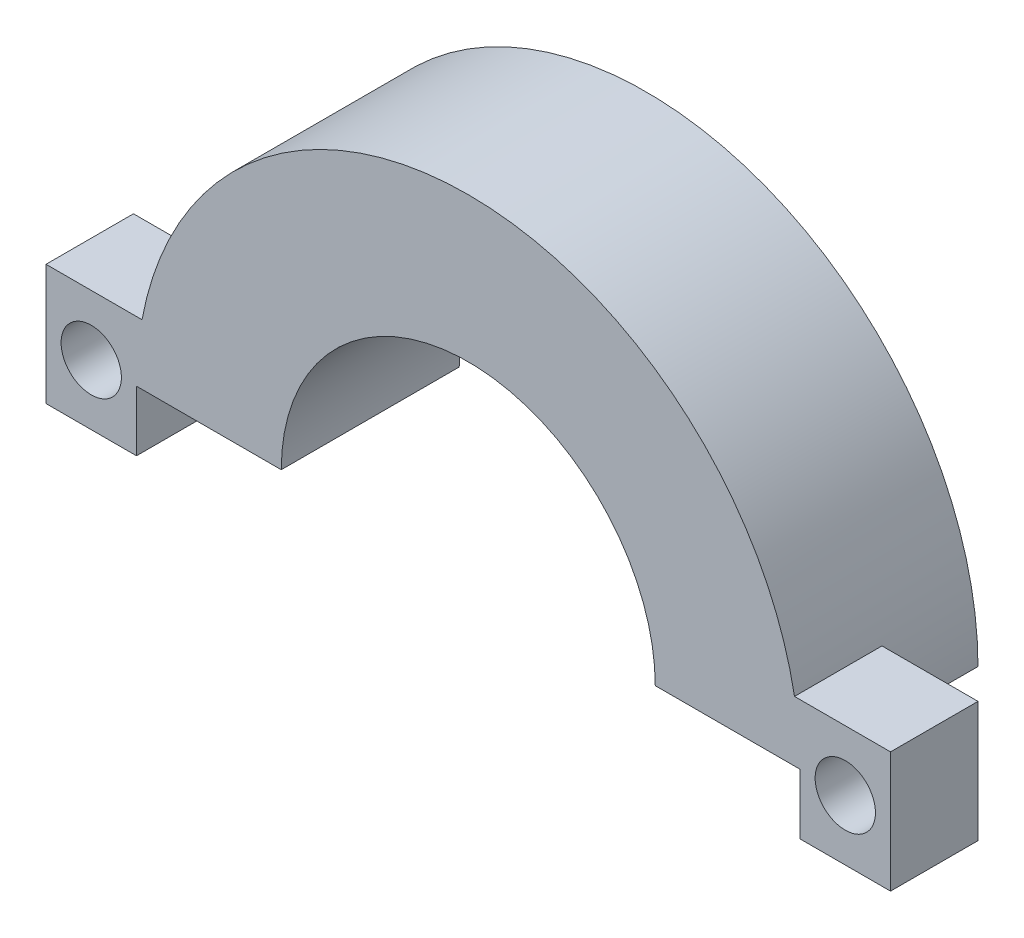
from build123d import *

# Parameters (mm, degrees)
RESSALTO_EXTRUS_O1_DEPTH = 5.9
RESSALTO_EXTRUS_O2_DEPTH = 2.9
ESBO_O3_R                = 1
CORTE_EXTRUS_O1_DEPTH    = 6.5


with BuildPart() as part:
    # Esboço1 → Ressalto-extrusão1 (new body)
    with BuildSketch(Plane.XY):
        with BuildLine():
            ThreePointArc((18.563238972, 0), (7.563238972, 11), (-3.436761028, 0))
            Line((-3.436761028, 0), (1.363238972, 0))
            ThreePointArc((1.363238972, 0), (7.563238972, 6.2), (13.763238972, 0))
            Line((13.763238972, 0), (18.563238972, 0))
        make_face()
    extrude(amount=RESSALTO_EXTRUS_O1_DEPTH)

    # Esboço2 → Ressalto-extrusão2 (add)
    with BuildSketch(Plane.XY.offset(5.9)):
        with BuildLine():
            ThreePointArc((-3.436761028, 0), (-3.390828585, 1.004193186), (-3.253414854, 2))
            Line((-3.253414854, 2), (-6.436761028, 2))
            Line((-6.436761028, 2), (-6.436761028, -2))
            Line((-6.436761028, -2), (-3.436761028, -2))
            Line((-3.436761028, -2), (-3.436761028, 0))
        make_face()
        with BuildLine():
            Line((-0.436761028, 2), (-3.253414854, 2))
            ThreePointArc((-3.253414854, 2), (-3.390828585, 1.004193186), (-3.436761028, 0))
            Line((-3.436761028, 0), (-0.436761028, 0))
            Line((-0.436761028, 0), (-0.436761028, 2))
        make_face()
        with BuildLine():
            ThreePointArc((18.379892799, 2), (18.517306529, 1.004193186), (18.563238972, 0))
            Line((18.563238972, 0), (18.563238972, -2))
            Line((18.563238972, -2), (21.563238972, -2))
            Line((21.563238972, -2), (21.563238972, 2))
            Line((21.563238972, 2), (18.379892799, 2))
        make_face()
        with BuildLine():
            Line((15.563238972, 0), (18.563238972, 0))
            ThreePointArc((18.563238972, 0), (18.517306529, 1.004193186), (18.379892799, 2))
            Line((18.379892799, 2), (15.563238972, 2))
            Line((15.563238972, 2), (15.563238972, 0))
        make_face()
    extrude(amount=-RESSALTO_EXTRUS_O2_DEPTH)

    # Esboço3 → Corte-extrusão1 (cut)
    with BuildSketch(Plane.XY.offset(5.9)):
        with Locations((20.063238972, 0)):
            Circle(ESBO_O3_R)
        with Locations((-4.936761028, 0)):
            Circle(ESBO_O3_R)
    extrude(amount=-CORTE_EXTRUS_O1_DEPTH, mode=Mode.SUBTRACT)


solid = part.part
